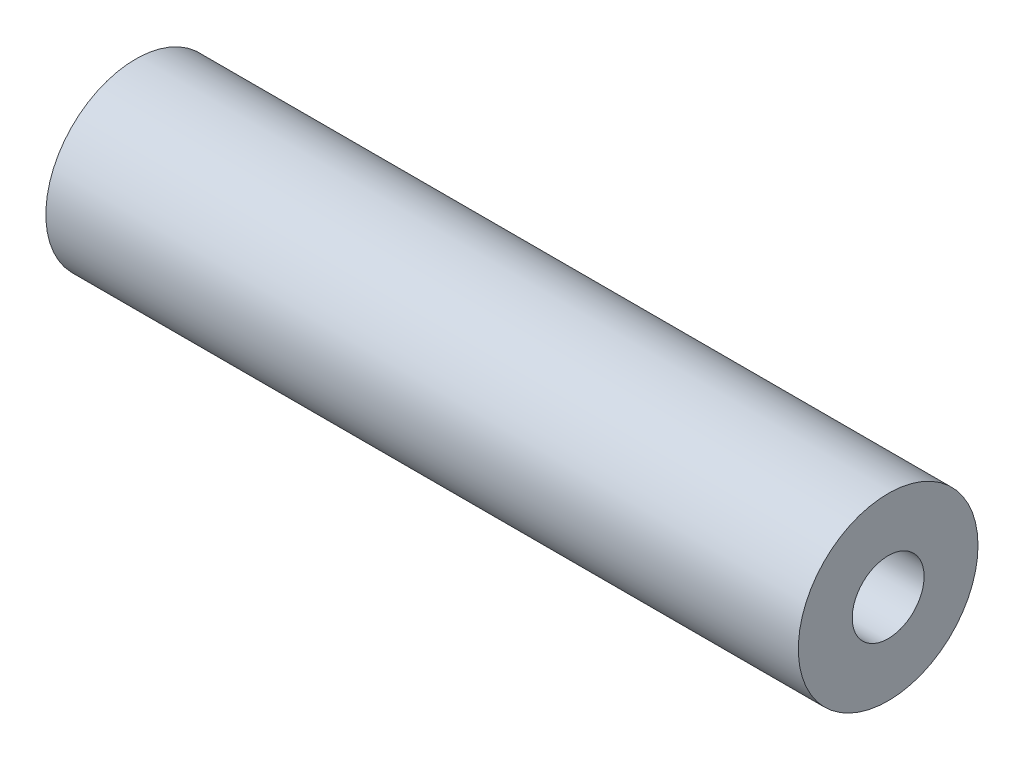
from build123d import *

# Parameters (mm, degrees)
CROQUIS1_R                       = 8
SALIENTE_EXTRUIR1_DEPTH          = 33.5
TALADRO_DE_MARGEN_PARA_M61_D     = 6.4
TALADRO_DE_MARGEN_PARA_M61_DEPTH = 20
TALADRO_DE_MARGEN_PARA_M61_TIP   = 1.922753981
TALADRO_DE_MARGEN_PARA_M62_D     = 6.4
TALADRO_DE_MARGEN_PARA_M62_DEPTH = 20
TALADRO_DE_MARGEN_PARA_M62_TIP   = 1.922753981


with BuildPart() as part:
    # Croquis1 → Saliente-Extruir1 (new body, symmetric)
    with BuildSketch(Plane(origin=(0, 0, 0), x_dir=(0, 0, -1), z_dir=(1, 0, 0))):
        Circle(CROQUIS1_R)
    extrude(amount=SALIENTE_EXTRUIR1_DEPTH, both=True)

    # Taladro de margen para M61
    with Locations(Plane.ZY.offset(33.5)):
        with Locations((0, 0)):
            Hole(TALADRO_DE_MARGEN_PARA_M61_D / 2, depth=TALADRO_DE_MARGEN_PARA_M61_DEPTH)
            with Locations((0, 0, -(TALADRO_DE_MARGEN_PARA_M61_DEPTH + TALADRO_DE_MARGEN_PARA_M61_TIP / 2))):  # 118° drill point
                Cone(0, TALADRO_DE_MARGEN_PARA_M61_D / 2, TALADRO_DE_MARGEN_PARA_M61_TIP, mode=Mode.SUBTRACT)

    # Taladro de margen para M62
    with Locations(Plane(origin=(33.5, 0, 0), x_dir=(0, 0, -1), z_dir=(1, 0, 0))):
        with Locations((0, 0)):
            Hole(TALADRO_DE_MARGEN_PARA_M62_D / 2, depth=TALADRO_DE_MARGEN_PARA_M62_DEPTH)
            with Locations((0, 0, -(TALADRO_DE_MARGEN_PARA_M62_DEPTH + TALADRO_DE_MARGEN_PARA_M62_TIP / 2))):  # 118° drill point
                Cone(0, TALADRO_DE_MARGEN_PARA_M62_D / 2, TALADRO_DE_MARGEN_PARA_M62_TIP, mode=Mode.SUBTRACT)


solid = part.part
